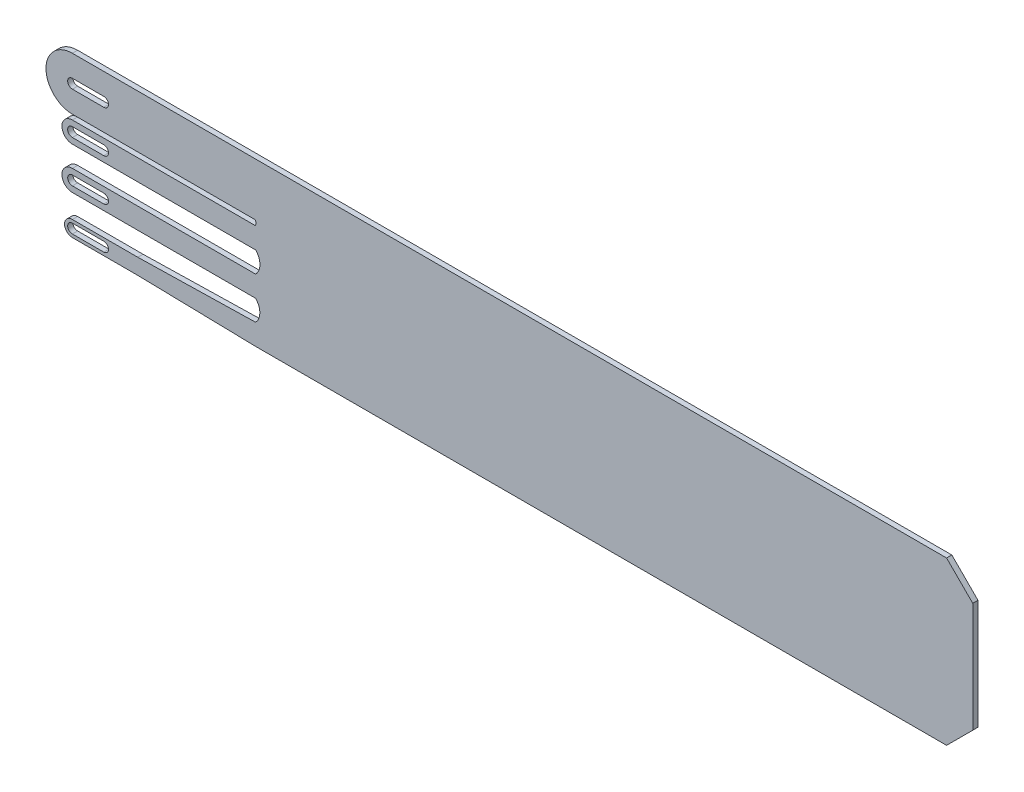
from build123d import *

# Parameters (mm, degrees)
BOSS_EXTRU_1_DEPTH = 1


with BuildPart() as part:
    # Esquisse4 → Boss.-Extru.1 (new body)
    with BuildSketch(Plane.XY):
        Polygon((109.153274168, 31.039696422), (109.153274168, 0.039696422), (132, 0.039696422), (137, 5.039696422), (137, 26.039696422), (132, 31.039696422), align=None)
        with BuildLine():
            Line((0, 4.039696422), (-22.5, 3.539696422))
            Line((-22.5, 3.539696422), (-22.5, 0.539696422))
            Line((-22.5, 0.539696422), (0, 0.039696422))
            Line((0, 0.039696422), (109.153274168, 0.039696422))
            Line((109.153274168, 0.039696422), (109.153274168, 31.039696422))
            Line((109.153274168, 31.039696422), (0, 31.039696422))
            Line((0, 31.039696422), (-35, 31.039696422))
            ThreePointArc((-35, 31.039696422), (-40.039696422, 26), (-35, 20.960303578))
            Line((-35, 20.960303578), (0, 20.960303578))
            ThreePointArc((0, 20.960303578), (0.041053045, 20.480151789), (0, 20))
            Line((0, 20), (-35, 20))
            ThreePointArc((-35, 20), (-37, 18), (-35, 16))
            Line((-35, 16), (0, 16))
            ThreePointArc((0, 16), (0.828427125, 14), (0, 12))
            Line((0, 12), (-22.5, 12))
            Line((-22.5, 12), (-22.5, 8))
            Line((-22.5, 8), (0, 8))
            ThreePointArc((0, 8), (0.808773964, 6.019848211), (0, 4.039696422))
        make_face()
        with BuildLine():
            ThreePointArc((-35, 17.1), (-35.9, 18), (-35, 18.9))
            Line((-35, 18.9), (-29, 18.9))
            ThreePointArc((-29, 18.9), (-28.1, 18), (-29, 17.1))
            Line((-29, 17.1), (-35, 17.1))
        make_face(mode=Mode.SUBTRACT)
        with BuildLine():
            ThreePointArc((-35, 25.1), (-35.9, 26), (-35, 26.9))
            Line((-35, 26.9), (-29, 26.9))
            ThreePointArc((-29, 26.9), (-28.1, 26), (-29, 25.1))
            Line((-29, 25.1), (-35, 25.1))
        make_face(mode=Mode.SUBTRACT)
        with BuildLine():
            Line((-35, 8), (-22.5, 8))
            Line((-22.5, 8), (-22.5, 12))
            Line((-22.5, 12), (-35, 12))
            ThreePointArc((-35, 12), (-37, 10), (-35, 8))
        make_face()
        with BuildLine():
            ThreePointArc((-35, 9.1), (-35.9, 10), (-35, 10.9))
            Line((-35, 10.9), (-29, 10.9))
            ThreePointArc((-29, 10.9), (-28.1, 10), (-29, 9.1))
            Line((-29, 9.1), (-35, 9.1))
        make_face(mode=Mode.SUBTRACT)
        with BuildLine():
            ThreePointArc((-35, 0.539696422), (-36.5, 2.039696422), (-35, 3.539696422))
            Line((-35, 3.539696422), (-22.5, 3.539696422))
            Line((-22.5, 3.539696422), (-22.5, 0.539696422))
            Line((-22.5, 0.539696422), (-35, 0.539696422))
        make_face()
        with BuildLine():
            ThreePointArc((-29, 1.139696422), (-28.1, 2.039696422), (-29, 2.939696422))
            Line((-29, 2.939696422), (-35, 2.939696422))
            ThreePointArc((-35, 2.939696422), (-35.9, 2.039696422), (-35, 1.139696422))
            Line((-35, 1.139696422), (-29, 1.139696422))
        make_face(mode=Mode.SUBTRACT)
    extrude(amount=BOSS_EXTRU_1_DEPTH)


solid = part.part
